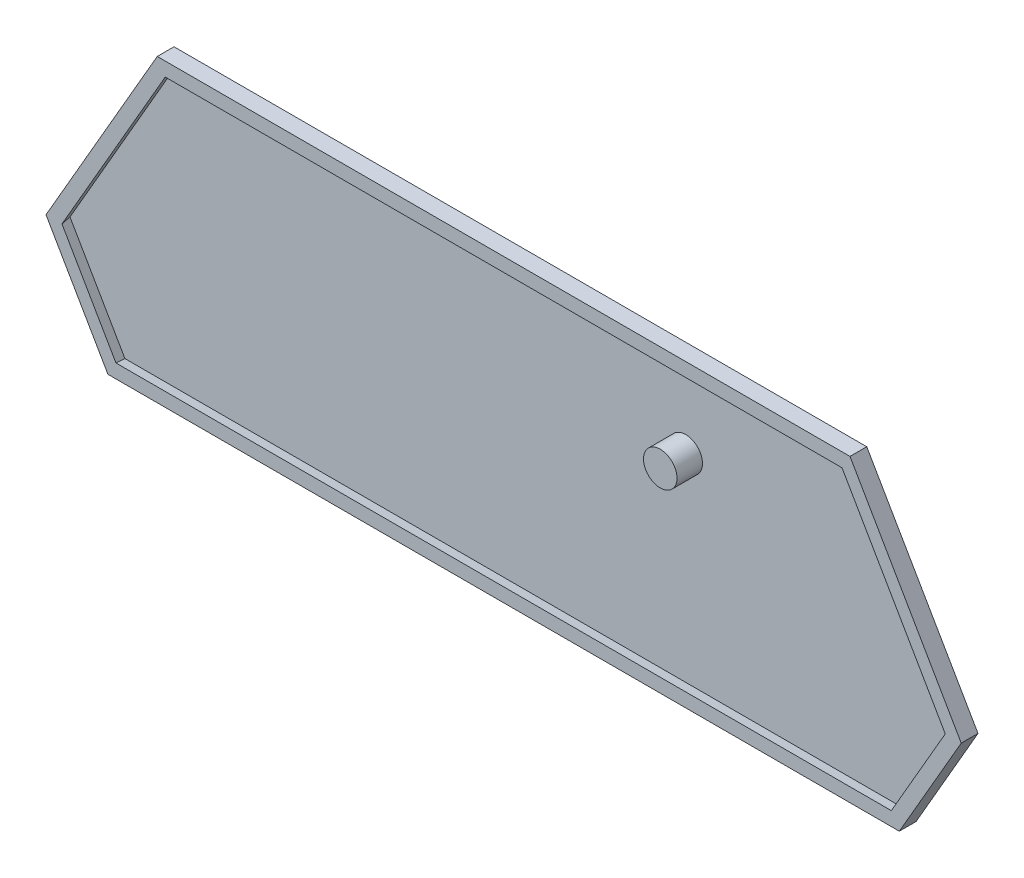
from build123d import *

# Parameters (mm, degrees)
BOSS_EXTRU_1_DEPTH              = 1
EXTRU_MINCE1_DEPTH              = 1.5
EXTRU_MINCE1_TAPER              = -10
ENL_V_DE_MAT_EXTRU_MINCE1_DEPTH = 3.5000001
ESQUISSE4_R                     = 2.5
BOSS_EXTRU_2_DEPTH              = 3.8


with BuildPart() as part:
    # Esquisse1 → Boss.-Extru.1 (new body)
    with BuildSketch(Plane.XY):
        Polygon((-59.024791386, -44.744645862), (2.7, -44.744645862), (59.024791386, -44.744645862), (68.262395693, -28.744645862), (51.666666667, 0), (-51.666666667, 0), (-68.262395693, -28.744645862), align=None)
    extrude(amount=BOSS_EXTRU_1_DEPTH)

    # Esquisse2 → Extru.-Mince1 (add)
    with BuildSketch(Plane.XY.offset(1)):
        Polygon((-68.262395693, -28.744645862), (-59.024791386, -44.744645862), (59.024791386, -44.744645862), (68.262395693, -28.744645862), (51.666666667, 0), (-51.666666667, 0), align=None)
        Polygon((-66.183934724, -28.744645862), (-57.985560901, -42.944645862), (57.985560901, -42.944645862), (66.183934724, -28.744645862), (50.627436182, -1.8), (-50.627436182, -1.8), align=None, mode=Mode.SUBTRACT)
    extrude(amount=EXTRU_MINCE1_DEPTH, taper=EXTRU_MINCE1_TAPER)

    # Esquisse3 → Enlèv. de mat.-Extru.-Mince1 (cut, through all)
    with BuildSketch(Plane(origin=(0, 0, 0), x_dir=(-1, 0, 0), z_dir=(0, 0, -1))):
        Polygon((60.121756897, -46.644645862), (70.456326716, -28.744645862), (52.763632178, 1.9), (-52.763632178, 1.9), (-70.456326716, -28.744645862), (-60.121756897, -46.644645862), align=None)
        Polygon((59.024791386, -44.744645862), (68.262395693, -28.744645862), (51.666666667, 0), (-51.666666667, 0), (-68.262395693, -28.744645862), (-59.024791386, -44.744645862), align=None, mode=Mode.SUBTRACT)
    extrude(amount=-ENL_V_DE_MAT_EXTRU_MINCE1_DEPTH, mode=Mode.SUBTRACT)

    # Esquisse4 → Boss.-Extru.2 (add)
    with BuildSketch(Plane.XY.offset(1)):
        with Locations((25.665479371, -13.424541306)):
            Circle(ESQUISSE4_R)
    extrude(amount=BOSS_EXTRU_2_DEPTH)


solid = part.part
